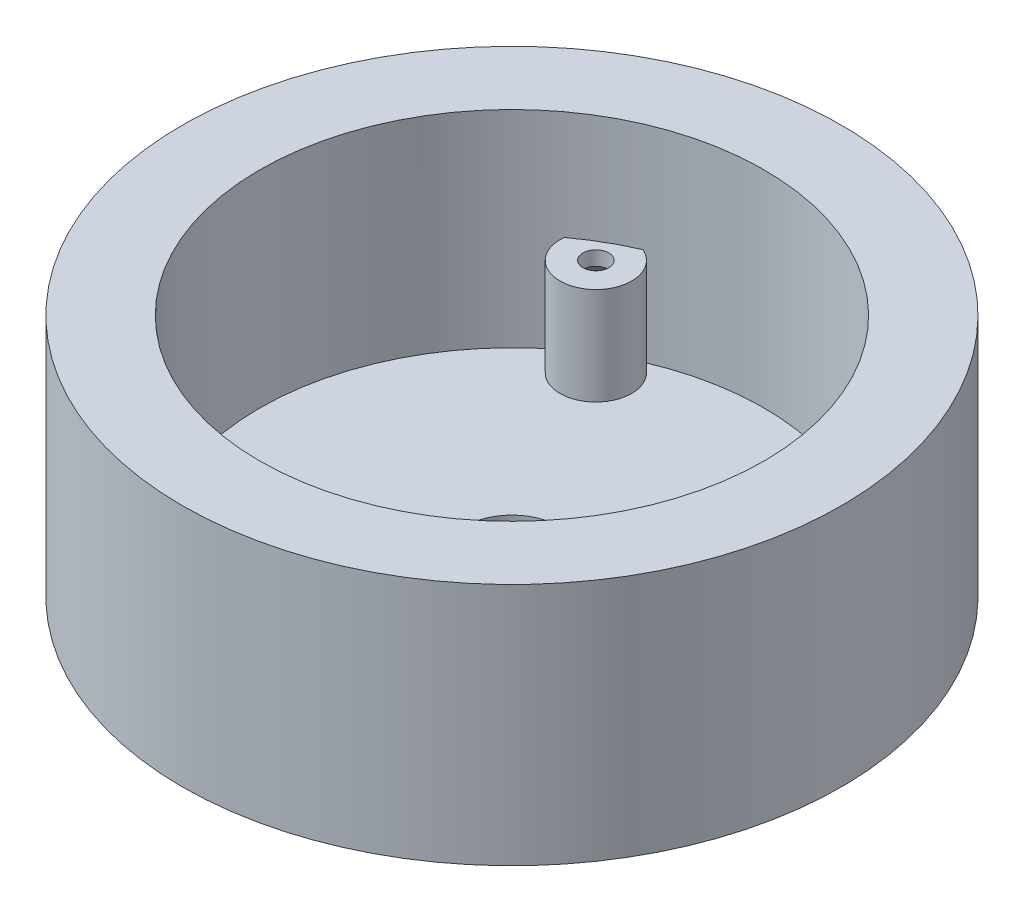
from build123d import *

# Parameters (mm, degrees)
SKETCH1_R                                    = 23
MAIN_BODY_DEPTH                              = 17
SHELL1_T                                     = -2.6
SKETCH22_R                                   = 20.400000000000006
SKETCH22_R_2                                 = 17.6
SIDE_PADDING_DEPTH                           = 14.4
SKETCH24_R                                   = 2.5000000000000004
SKETCH24_R_2                                 = 2.4999999999999982
SCREW_SUPPORTS_DEPTH                         = 6.8
CSK_SLOT_FOR_M1_6_COUNTERSUNK_FLAT_H_2_COUNT = 2
CSK_SLOT_FOR_M1_6_COUNTERSUNK_FLAT_H_2_PITCH = 27.712812921102078
CSK_SLOT_FOR_M1_6_COUNTERSUNK_FLAT_H_3_COUNT = 2
CSK_SLOT_FOR_M1_6_COUNTERSUNK_FLAT_H_3_PITCH = 27.712812921101964
CONNECTOR_BODY_DEPTH                         = 6
SKETCH29_W                                   = 1.9999999999999991
SKETCH29_H                                   = 3
CONNECTOR_CUTS_DEPTH                         = 47.00572879607992
FILLET2_R                                    = 2
POGO_HOLE_DEPTH                              = 4.5
POGO_TOP_SUPPORT_DEPTH                       = 0.6
POGO_BACK_SUPPORT_DEPTH                      = 0.6
MIDDLE_WIRE_CUT_DEPTH                        = 40.83716857408418
SKETCH35_R                                   = 3.3000000000000003
SLIP_RING_HOLE_DEPTH                         = 36.57189902155914


with BuildPart() as part:
    # Sketch1 → main body (new body)
    with BuildSketch(Plane(origin=(0, 0, 0), x_dir=(1, 0, 0), z_dir=(0, 1, 0))):
        with Locations(Location((0, 0, 0), (0, 0, 270))):
            Circle(SKETCH1_R)
    extrude(amount=MAIN_BODY_DEPTH)

    # Shell1
    shell1_openings = [part.faces().sort_by_distance(p)[0] for p in [
        (0, 17, 0),
    ]]
    offset(amount=SHELL1_T, openings=shell1_openings, kind=Kind.INTERSECTION)

    # Sketch22 → side padding (add)
    with BuildSketch(Plane(origin=(0, 2.6, 0), x_dir=(1, 0, 0), z_dir=(0, 1, 0))):
        Circle(SKETCH22_R)
        with Locations(Location((0, 0, 0), (0, 0, 270))):
            Circle(SKETCH22_R_2, mode=Mode.SUBTRACT)
    extrude(amount=SIDE_PADDING_DEPTH)

    # Sketch24 → screw supports (add)
    with BuildSketch(Plane(origin=(0, 2.6, 0), x_dir=(1, 0, 0), z_dir=(0, 1, 0))):
        with Locations((-8.000000000000066, 13.856406460550984)):
            Circle(SKETCH24_R)
        with Locations((16.00000000000061, 1.09033e-12)):
            Circle(SKETCH24_R_2)
        with Locations((-7.999999999998755, -13.856406460551078)):
            Circle(SKETCH24_R)
    extrude(amount=SCREW_SUPPORTS_DEPTH)

    # Sketch26 → CSK SLOT for M1.6 Countersunk Flat Head Screw2 (revolve, cut)
    with BuildSketch(Plane(origin=(-7.999999999999872, 0, 13.856406460551092), x_dir=(0, 0, -1), z_dir=(1, 0, 0))):
        Polygon((0, 0), (-4.16e-15, 17), (0.899999999999995, 17), (0.899999999999999, 8.4), (1.799999999999998, 7.5), (1.7999999999999996, -3.47e-15), align=None)
    csk_slot_for_m1_6_countersunk_flat_head = revolve(axis=Axis((-7.999999999999872, -6.349999999999991, 13.856406460551092), (0, 1, 0)), mode=Mode.SUBTRACT)

    # CSK SLOT for M1.6 Countersunk Flat H 2: CSK SLOT for M1.6 Countersunk Flat Head Screw2 ×2
    with Locations(*[(0, 0, -i * CSK_SLOT_FOR_M1_6_COUNTERSUNK_FLAT_H_2_PITCH) for i in range(1, CSK_SLOT_FOR_M1_6_COUNTERSUNK_FLAT_H_2_COUNT)]):
        add(csk_slot_for_m1_6_countersunk_flat_head, mode=Mode.SUBTRACT)

    # CSK SLOT for M1.6 Countersunk Flat H 3: CSK SLOT for M1.6 Countersunk Flat Head Screw2 ×2
    with Locations(*[Vector(0.8660254037844364, 0, -0.5000000000000041) * (i * CSK_SLOT_FOR_M1_6_COUNTERSUNK_FLAT_H_3_PITCH) for i in range(1, CSK_SLOT_FOR_M1_6_COUNTERSUNK_FLAT_H_3_COUNT)]):
        add(csk_slot_for_m1_6_countersunk_flat_head, mode=Mode.SUBTRACT)

    # Sketch28 → connector body (add)
    with BuildSketch(Plane.XZ):
        Polygon((2.0319134377332504, -16.7026098711818), (13.309106732280016, -10.235391659506115), (0.3746703089286471, 12.318994929587399), (-10.90252298561811, 5.8517767179117195), align=None)
    extrude(amount=CONNECTOR_BODY_DEPTH)

    # Sketch29 → connector cuts (cut, through all)
    with BuildSketch(Plane(origin=(-5.223545835654305, 0, 9.108543139189257), x_dir=(0.8674764072728275, 0, 0.4974783239750529), z_dir=(-0.4974783239750529, 0, 0.8674764072728275))):
        with Locations((-5.5465493958704535, -1.5)):
            Rectangle(SKETCH29_W, SKETCH29_H)
        Polygon((6.453450604129538, 1.59e-15), (6.453450604129538, -2.9999999999999982), (4.453450604129538, -2.9999999999999987), (4.453450604129538, 1.1e-15), align=None)
    extrude(amount=-CONNECTOR_CUTS_DEPTH, mode=Mode.SUBTRACT)

    # Fillet2
    fillet2_edges = [part.edges().sort_by_distance(p)[0] for p in [
        (-10.90252298561811, -4.5, 5.8517767179117195),
        (0.3746703089286471, -4.499999999999999, 12.318994929587399),
        (-5.263926338344731, -6, 9.08538582374956),
    ]]
    fillet(fillet2_edges, radius=FILLET2_R)

    # Sketch30 → pogo hole (cut)
    with BuildSketch(Plane(origin=(-5.223545835654305, 0, 9.108543139189257), x_dir=(0.8674764072728275, 0, 0.4974783239750529), z_dir=(-0.4974783239750529, 0, 0.8674764072728275))):
        Polygon((3.953450604129541, -2.6999999999999975), (-4.046549395870457, -2.7), (-4.046549395870457, -6), (3.953450604129543, -5.999999999999997), align=None)
    extrude(amount=-POGO_HOLE_DEPTH, mode=Mode.SUBTRACT)

    # Sketch31 → pogo top support (add)
    with BuildSketch(Plane.XZ.offset(6)):
        Polygon((-6.495179509548303, 3.1918286951216346), (0.44463174863431776, 7.171655286922058), (-1.1472988880858548, 9.947579790195107), (-8.087110146268472, 5.967753198394682), align=None)
    extrude(amount=-POGO_TOP_SUPPORT_DEPTH)

    # Sketch33 → pogo back support (add)
    with BuildSketch(Plane(origin=(0, -5.4, 0), x_dir=(1, 0, 0), z_dir=(0, 1, 0))):
        Polygon((-6.4951795095483025, -3.191828695121635), (0.44463174863431776, -7.171655286922058), (-0.5503248993157871, -8.906608101467711), (-7.490136157498408, -4.926781509667289), align=None)
    extrude(amount=POGO_BACK_SUPPORT_DEPTH)

    # Sketch34 → middle wire cut (cut, through all)
    with BuildSketch(Plane.XZ.offset(6)):
        Polygon((-6.352157331722817, 6.962709846344788), (-3.1185482258849735, 1.3241131990714121), (0.35135740320633424, 3.314026494971624), (-2.8822517026315113, 8.952623142245), align=None)
    extrude(amount=-MIDDLE_WIRE_CUT_DEPTH, mode=Mode.SUBTRACT)

    # Sketch35 → slip ring hole (cut, through all)
    with BuildSketch(Plane(origin=(0, 2.6, 0), x_dir=(1, 0, 0), z_dir=(0, 1, 0))):
        Circle(SKETCH35_R)
    extrude(amount=-SLIP_RING_HOLE_DEPTH, mode=Mode.SUBTRACT)


solid = part.part
